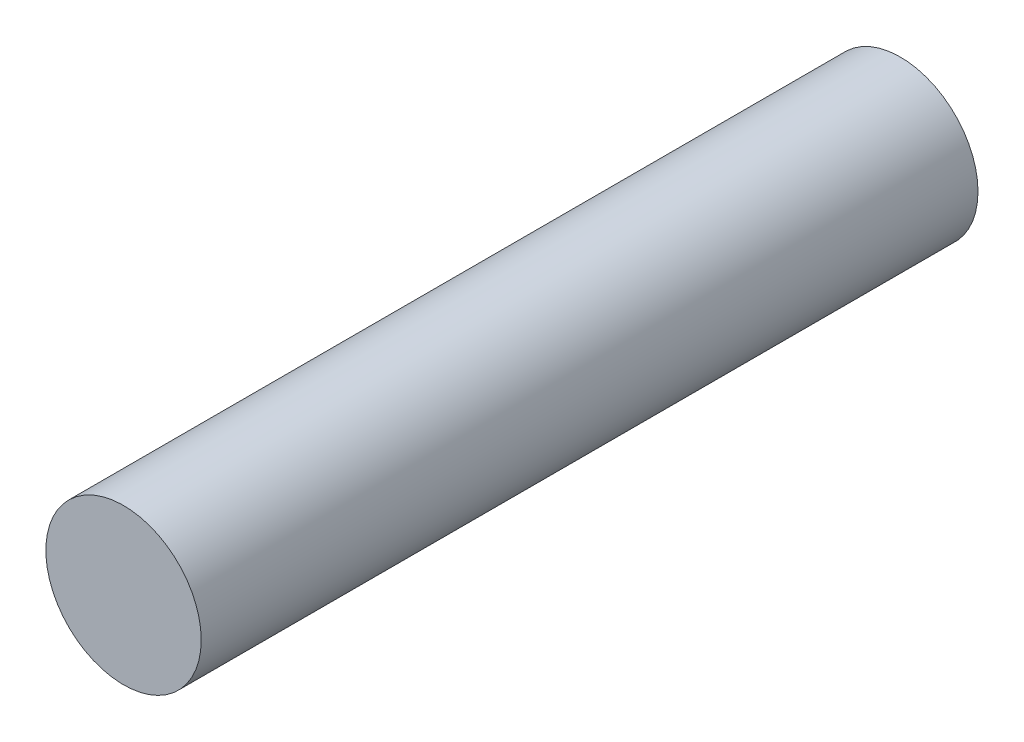
from build123d import *

# Parameters (mm, degrees)
SKETCH1_R           = 3.175
BOSS_EXTRUDE1_DEPTH = 31.75


with BuildPart() as part:
    # Sketch1 → Boss-Extrude1 (new body)
    with BuildSketch(Plane.XY):
        Circle(SKETCH1_R)
    extrude(amount=BOSS_EXTRUDE1_DEPTH)


solid = part.part
